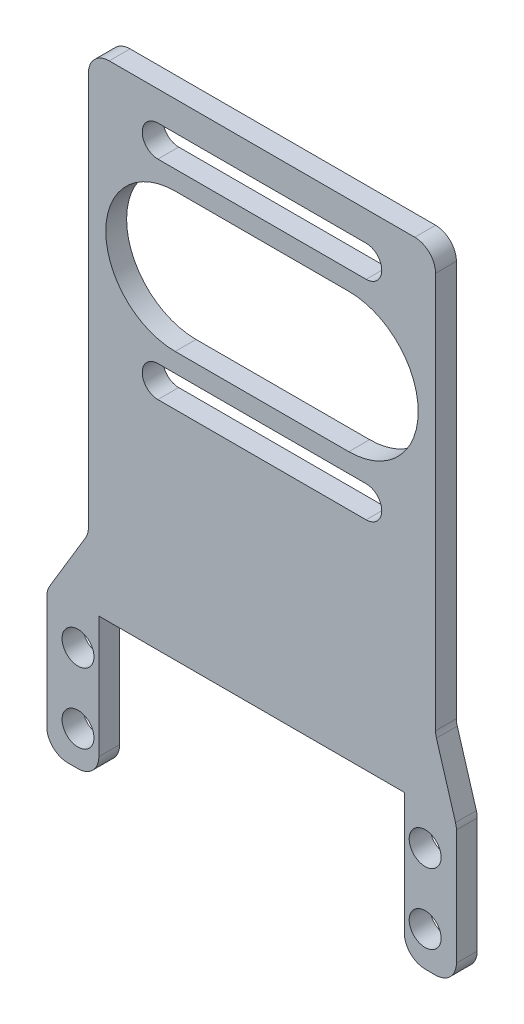
from build123d import *

# Parameters (mm, degrees)
SKETCH1_R           = 2.3
BOSS_EXTRUDE1_DEPTH = 3
FILLET1_R           = 3


with BuildPart() as part:
    # Sketch1 → Boss-Extrude1 (new body)
    with BuildSketch(Plane.XY):
        Polygon((7.5, -20.05), (0, -20.05), (0, 0), (6, 10), (6, 70.5), (56, 70.5), (56, 10), (59, 0), (59, -20.05), (51.5, -20.05), (51.5, 0.5), (7.5, 0.5), align=None)
        with Locations((4.5, -15.05)):
            Circle(SKETCH1_R, mode=Mode.SUBTRACT)
        with Locations((4.5, -4.95)):
            Circle(SKETCH1_R, mode=Mode.SUBTRACT)
        with Locations((54.5, -15.05)):
            Circle(SKETCH1_R, mode=Mode.SUBTRACT)
        with Locations((54.5, -4.95)):
            Circle(SKETCH1_R, mode=Mode.SUBTRACT)
        with BuildLine():
            Line((18.5, 59), (43.5, 59))
            ThreePointArc((43.5, 59), (53.5, 49), (43.5, 39))
            Line((43.5, 39), (18.5, 39))
            ThreePointArc((18.5, 39), (8.5, 49), (18.5, 59))
        make_face(mode=Mode.SUBTRACT)
        with BuildLine():
            Line((16, 66.25), (46, 66.25))
            ThreePointArc((46, 66.25), (48.25, 64), (46, 61.75))
            Line((46, 61.75), (16, 61.75))
            ThreePointArc((16, 61.75), (13.75, 64), (16, 66.25))
        make_face(mode=Mode.SUBTRACT)
        with BuildLine():
            Line((16, 36.25), (46, 36.25))
            ThreePointArc((46, 36.25), (48.25, 34), (46, 31.75))
            Line((46, 31.75), (16, 31.75))
            ThreePointArc((16, 31.75), (13.75, 34), (16, 36.25))
        make_face(mode=Mode.SUBTRACT)
    extrude(amount=BOSS_EXTRUDE1_DEPTH)

    # Fillet1
    fillet1_edges = [part.edges().sort_by_distance(p)[0] for p in [
        (0, 0, 1.5),
        (6, 10, 1.5),
        (6, 70.5, 1.5),
        (56, 70.5, 1.5),
        (56, 10, 1.5),
        (59, 0, 1.5),
        (59, -20.05, 1.5),
        (51.5, -20.05, 1.5),
        (7.5, -20.05, 1.5),
        (0, -20.05, 1.5),
    ]]
    fillet(fillet1_edges, radius=FILLET1_R)


solid = part.part
